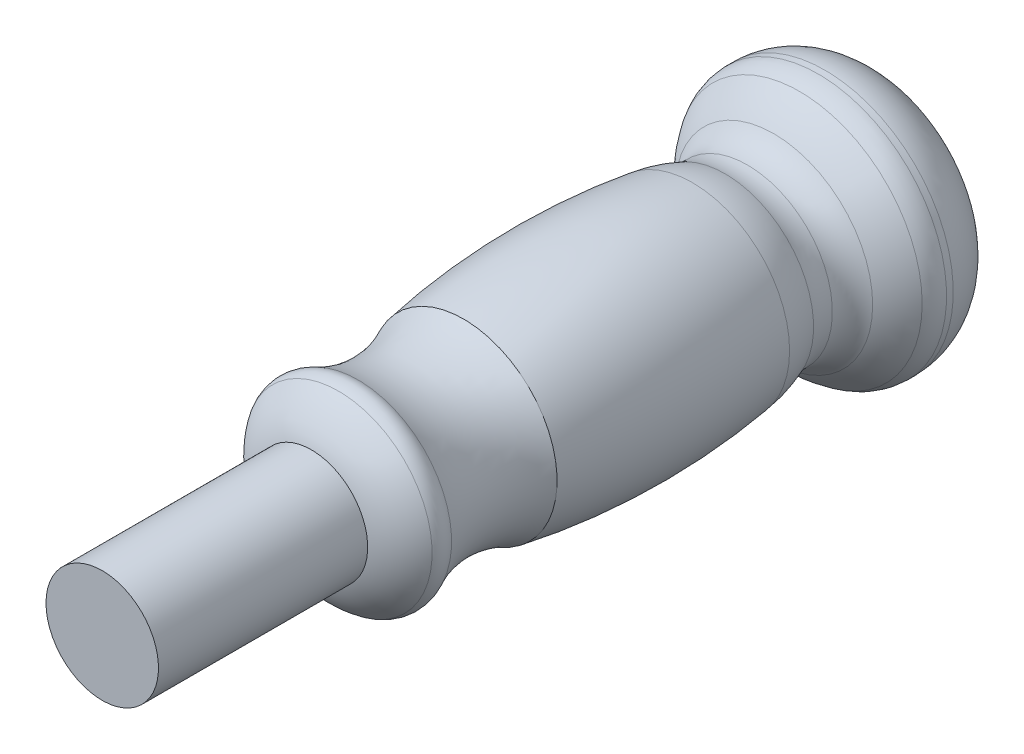
from build123d import *


with BuildPart() as part:
    # Sketch1 → Revolve5 (revolve)
    with BuildSketch(Plane(origin=(0, 0, 0), x_dir=(1, 0, 0), z_dir=(0, 1, 0))):
        with BuildLine():
            Line((-10.922, 0), (0, 0))
            Line((0, 0), (0, 152.4))
            Line((0, 152.4), (-14.648177892, 152.4))
            ThreePointArc((-14.648177892, 152.4), (-21.86995116, 148.183685931), (-24.9064291, 140.391952157))
            Line((-24.9064291, 140.391952157), (-24.9064291, 139.097981176))
            ThreePointArc((-24.9064291, 139.097981176), (-24.629788113, 137.189360348), (-23.822633993, 135.437827898))
            ThreePointArc((-23.822633993, 135.437827898), (-21.727400877, 132.742183052), (-19.206488947, 130.43968311))
            ThreePointArc((-19.206488947, 130.43968311), (-17.294597423, 128.178783744), (-16.491603127, 125.3288372))
            ThreePointArc((-16.491603127, 125.3288372), (-16.597847922, 123.122602782), (-17.179160796, 120.991679599))
            ThreePointArc((-17.179160796, 120.991679599), (-18.199132155, 117.877020277), (-18.845657016, 114.664007692))
            ThreePointArc((-18.845657016, 114.664007692), (-20.226314555, 92.4045447), (-18.146310091, 70.199511728))
            ThreePointArc((-18.146310091, 70.199511728), (-15.781686007, 59.957518133), (-18.146310091, 49.715524538))
            ThreePointArc((-18.146310091, 49.715524538), (-18.678899818, 47.821248891), (-18.146310091, 45.926973244))
            ThreePointArc((-18.146310091, 45.926973244), (-14.978108994, 42.676852004), (-10.922, 40.64))
            Line((-10.922, 40.64), (-10.922, 0))
        make_face()
    revolve(axis=Axis((0, 0, -152.4), (0, 0, 1)))


solid = part.part
